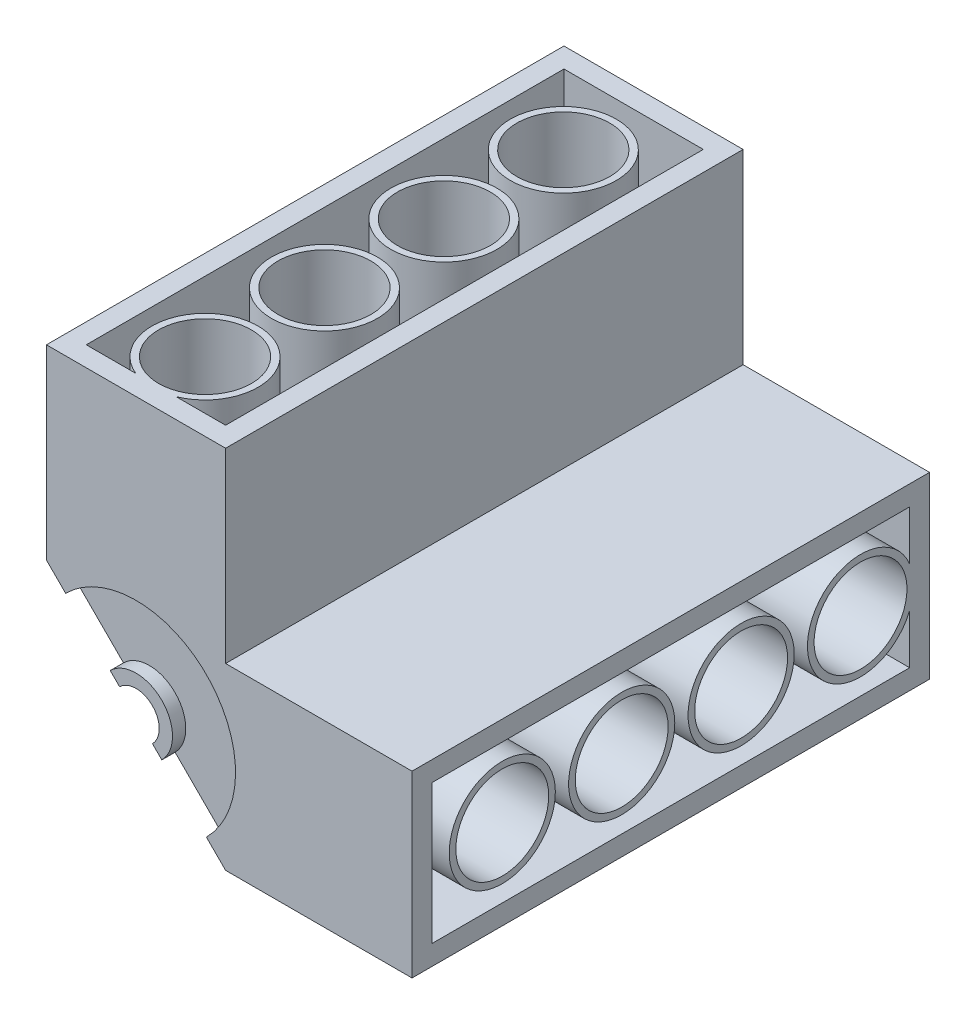
from build123d import *

# Parameters (mm, degrees)
SALIENTE_EXTRUIR4_DEPTH    = 390
SALIENTE_EXTRUIR5_START    = 10
SALIENTE_EXTRUIR5_DEPTH    = 10
SALIENTE_EXTRUIR6_DEPTH    = 30
MATRIZL1_COUNT             = 5
MATRIZL1_PITCH             = 90
CROQUIS6_W                 = 360
CROQUIS6_H                 = 105
CORTAR_EXTRUIR2_DEPTH      = 120
CORTAR_EXTRUIR7_REACH      = 522.83
CORTAR_EXTRUIR7_END_RADIUS = 75
CROQUIS16_R                = 35
SALIENTE_EXTRUIR10_REACH   = 522.83
CROQUIS17_R                = 40
CROQUIS17_R_2              = 35
CORTAR_EXTRUIR8_REACH      = 522.83
CORTAR_EXTRUIR8_END_RADIUS = 75
CROQUIS18_R                = 35
SALIENTE_EXTRUIR11_REACH   = 522.83
CROQUIS19_R                = 40
CROQUIS19_R_2              = 35
MATRIZL7_COUNT             = 4
MATRIZL7_PITCH             = 90
MATRIZL10_COUNT            = 4
MATRIZL10_PITCH            = 90


with BuildPart() as part:
    # Croquis1 → Saliente-Extruir4 (new body)
    with BuildSketch(Plane.XY):
        with BuildLine():
            Line((-67.5, 208), (-67.5, 67.5))
            Line((-67.5, 67.5), (-53.033008589, 53.033008589))
            ThreePointArc((-53.033008589, 53.033008589), (53.033008589, 53.033008589), (53.033008589, -53.033008589))
            Line((53.033008589, -53.033008589), (67.5, -67.5))
            Line((67.5, -67.5), (208, -67.5))
            Line((208, -67.5), (208, 67.5))
            Line((208, 67.5), (67.5, 67.5))
            Line((67.5, 67.5), (67.5, 208))
            Line((67.5, 208), (-67.5, 208))
        make_face()
    extrude(amount=SALIENTE_EXTRUIR4_DEPTH)

    # Croquis1_7 → Saliente-Extruir5 (add)
    with BuildSketch(Plane.XY.offset(SALIENTE_EXTRUIR5_START)):
        with BuildLine():
            ThreePointArc((53.033008589, -53.033008589), (53.033008589, 53.033008589), (-53.033008589, 53.033008589))
            Line((-53.033008589, 53.033008589), (-19.445436483, 19.445436483))
            ThreePointArc((-19.445436483, 19.445436483), (19.445436483, 19.445436483), (19.445436483, -19.445436483))
            Line((19.445436483, -19.445436483), (53.033008589, -53.033008589))
        make_face()
    saliente_extruir5 = extrude(amount=SALIENTE_EXTRUIR5_DEPTH)

    # Croquis1_8 → Saliente-Extruir6 (add)
    with BuildSketch(Plane.XY):
        with BuildLine():
            ThreePointArc((19.445436483, -19.445436483), (19.445436483, 19.445436483), (-19.445436483, 19.445436483))
            Line((-19.445436483, 19.445436483), (-12.374368671, 12.374368671))
            ThreePointArc((-12.374368671, 12.374368671), (12.374368671, 12.374368671), (12.374368671, -12.374368671))
            Line((12.374368671, -12.374368671), (19.445436483, -19.445436483))
        make_face()
    saliente_extruir6 = extrude(amount=SALIENTE_EXTRUIR6_DEPTH)

    # MatrizL1: Saliente-Extruir5, Saliente-Extruir6 ×5
    with Locations(*[(0, 0, i * MATRIZL1_PITCH) for i in range(1, MATRIZL1_COUNT)]):
        add(saliente_extruir5)
        add(saliente_extruir6)

    # Croquis6 → Cortar-Extruir2 (cut)
    with BuildSketch(Plane(origin=(208, 0, 0), x_dir=(0, 0, -1), z_dir=(1, 0, 0))):
        with Locations((-195, 0)):
            Rectangle(CROQUIS6_W, CROQUIS6_H)
    cortar_extruir2 = extrude(amount=-CORTAR_EXTRUIR2_DEPTH, mode=Mode.SUBTRACT)

    # Simetría2: Cortar-Extruir2 across plane
    add(cortar_extruir2.mirror(Plane(origin=(0, 0, 0), x_dir=(0, 0, 1), z_dir=(0.7071067811865488, -0.7071067811865464, 0))), mode=Mode.SUBTRACT)

    # Cortar-Extruir7: up to this cylinder (the profile starts outside it)
    cortar_extruir7_end = Plane(origin=(0, 0, 52), z_dir=(0, 0, -1)) * Cylinder(CORTAR_EXTRUIR7_END_RADIUS, 1196.66, mode=Mode.PRIVATE)
    # Croquis16 → Cortar-Extruir7 (cut, up to the surface)
    with BuildSketch(Plane(origin=(208, 0, 0), x_dir=(0, 0, -1), z_dir=(1, 0, 0)), mode=Mode.PRIVATE) as cortar_extruir7_sk1:
        with Locations(Location((-52, 0, 0), (0, 0, 336.104493243))):
            Circle(CROQUIS16_R)
    cortar_extruir7_tool1 = extrude(cortar_extruir7_sk1.sketch, amount=-CORTAR_EXTRUIR7_REACH, mode=Mode.PRIVATE) - cortar_extruir7_end
    cortar_extruir7 = cortar_extruir7_tool1.solids().sort_by_distance((208, 0, 52))[0]
    add(cortar_extruir7, mode=Mode.SUBTRACT)

    # Croquis17 → Saliente-Extruir10 (add, up to next)
    with BuildSketch(Plane(origin=(208, 0, 0), x_dir=(0, 0, -1), z_dir=(1, 0, 0)), mode=Mode.PRIVATE) as saliente_extruir10_sk1:
        with Locations((-52, 0)):
            Circle(CROQUIS17_R)
        with Locations((-52, 0)):
            Circle(CROQUIS17_R_2, mode=Mode.SUBTRACT)
    saliente_extruir10_tool1 = extrude(saliente_extruir10_sk1.sketch, amount=-SALIENTE_EXTRUIR10_REACH, mode=Mode.PRIVATE) - part.part
    saliente_extruir10 = saliente_extruir10_tool1.solids().sort_by_distance((208, 0, 90.868629))[0]
    add(saliente_extruir10)

    # Cortar-Extruir8: up to this cylinder (the profile starts outside it)
    cortar_extruir8_end = Plane(origin=(0, 0, 338), z_dir=(0, 0, -1)) * Cylinder(CORTAR_EXTRUIR8_END_RADIUS, 1196.66, mode=Mode.PRIVATE)
    # Croquis18 → Cortar-Extruir8 (cut, up to the surface)
    with BuildSketch(Plane(origin=(0, 208, 0), x_dir=(1, 0, 0), z_dir=(0, 1, 0)), mode=Mode.PRIVATE) as cortar_extruir8_sk1:
        with Locations(Location((0, -338, 0), (0, 0, 246.104493243))):
            Circle(CROQUIS18_R)
    cortar_extruir8_tool1 = extrude(cortar_extruir8_sk1.sketch, amount=-CORTAR_EXTRUIR8_REACH, mode=Mode.PRIVATE) - cortar_extruir8_end
    cortar_extruir8 = cortar_extruir8_tool1.solids().sort_by_distance((0, 208, 338))[0]
    add(cortar_extruir8, mode=Mode.SUBTRACT)

    # Croquis19 → Saliente-Extruir11 (add, up to next)
    with BuildSketch(Plane(origin=(0, 208, 0), x_dir=(1, 0, 0), z_dir=(0, 1, 0)), mode=Mode.PRIVATE) as saliente_extruir11_sk1:
        with Locations((0, -338)):
            Circle(CROQUIS19_R)
        with Locations(Location((0, -338, 0), (0, 0, 270))):
            Circle(CROQUIS19_R_2, mode=Mode.SUBTRACT)
    saliente_extruir11_tool1 = extrude(saliente_extruir11_sk1.sketch, amount=-SALIENTE_EXTRUIR11_REACH, mode=Mode.PRIVATE) - part.part
    saliente_extruir11 = saliente_extruir11_tool1.solids().sort_by_distance((-38.868629, 208, 338))[0]
    add(saliente_extruir11)

    # MatrizL7: Cortar-Extruir8, Saliente-Extruir11; each copy of Saliente-Extruir11 runs up to whatever stops it at its own place
    matrizl7_before = part.part  # the part as the pattern finds it: every copy runs up to it
    add(cortar_extruir8.moved(Location(Vector(0, 0, -1) * (1 * MATRIZL7_PITCH))), mode=Mode.SUBTRACT)
    add(cortar_extruir8.moved(Location(Vector(0, 0, -1) * (2 * MATRIZL7_PITCH))), mode=Mode.SUBTRACT)
    add(cortar_extruir8.moved(Location(Vector(0, 0, -1) * (3 * MATRIZL7_PITCH))), mode=Mode.SUBTRACT)
    matrizl7_saliente_extruir11_long = extrude(saliente_extruir11_sk1.sketch, amount=-SALIENTE_EXTRUIR11_REACH, mode=Mode.PRIVATE)
    matrizl7_saliente_extruir11_tool = matrizl7_saliente_extruir11_long.moved(Location(Vector(0, 0, -1) * (1 * MATRIZL7_PITCH))) - matrizl7_before
    add(matrizl7_saliente_extruir11_tool.solids().sort_by_distance((-38.868629, 208, 248))[0])
    matrizl7_saliente_extruir11_tool = matrizl7_saliente_extruir11_long.moved(Location(Vector(0, 0, -1) * (2 * MATRIZL7_PITCH))) - matrizl7_before
    add(matrizl7_saliente_extruir11_tool.solids().sort_by_distance((-38.868629, 208, 158))[0])
    matrizl7_saliente_extruir11_tool = matrizl7_saliente_extruir11_long.moved(Location(Vector(0, 0, -1) * (3 * MATRIZL7_PITCH))) - matrizl7_before
    add(matrizl7_saliente_extruir11_tool.solids().sort_by_distance((-38.868629, 208, 68))[0])

    # MatrizL10: Cortar-Extruir7, Saliente-Extruir10; each copy of Saliente-Extruir10 runs up to whatever stops it at its own place
    matrizl10_before = part.part  # the part as the pattern finds it: every copy runs up to it
    add(cortar_extruir7.moved(Location(Vector(0, 0, 1) * (1 * MATRIZL10_PITCH))), mode=Mode.SUBTRACT)
    add(cortar_extruir7.moved(Location(Vector(0, 0, 1) * (2 * MATRIZL10_PITCH))), mode=Mode.SUBTRACT)
    add(cortar_extruir7.moved(Location(Vector(0, 0, 1) * (3 * MATRIZL10_PITCH))), mode=Mode.SUBTRACT)
    matrizl10_saliente_extruir10_long = extrude(saliente_extruir10_sk1.sketch, amount=-SALIENTE_EXTRUIR10_REACH, mode=Mode.PRIVATE)
    matrizl10_saliente_extruir10_tool = matrizl10_saliente_extruir10_long.moved(Location(Vector(0, 0, 1) * (1 * MATRIZL10_PITCH))) - matrizl10_before
    add(matrizl10_saliente_extruir10_tool.solids().sort_by_distance((208, 0, 180.868629))[0])
    matrizl10_saliente_extruir10_tool = matrizl10_saliente_extruir10_long.moved(Location(Vector(0, 0, 1) * (2 * MATRIZL10_PITCH))) - matrizl10_before
    add(matrizl10_saliente_extruir10_tool.solids().sort_by_distance((208, 0, 270.868629))[0])
    matrizl10_saliente_extruir10_tool = matrizl10_saliente_extruir10_long.moved(Location(Vector(0, 0, 1) * (3 * MATRIZL10_PITCH))) - matrizl10_before
    add(matrizl10_saliente_extruir10_tool.solids().sort_by_distance((208, 0, 360.868629))[0])


solid = part.part
